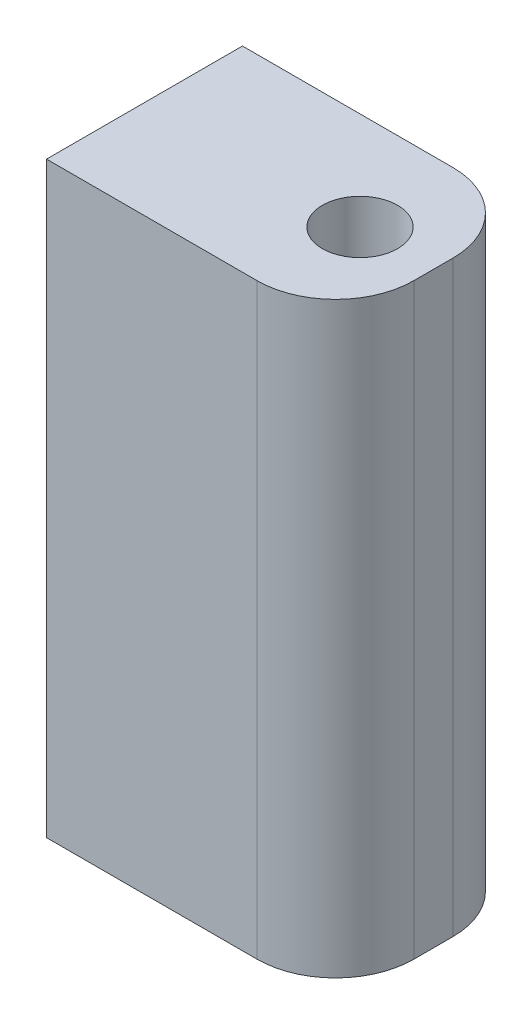
from build123d import *

# Parameters (mm, degrees)
SKETCH1_W                 = 10
SKETCH1_H                 = 19.05
BOSS_EXTRUDE1_DEPTH       = 3.175
F_2_CLEARANCE_HOLE1_D     = 2.4384
F_2_CLEARANCE_HOLE1_DEPTH = 6.35
F_2_CLEARANCE_HOLE1_TIP   = 0.732569267
F_2_CLEARANCE_HOLE2_D     = 2.4384
F_2_CLEARANCE_HOLE2_DEPTH = 6.35
F_2_CLEARANCE_HOLE2_TIP   = 0.732569267
FILLET1_R                 = 1.5875
SKETCH7_W                 = 0.635
SKETCH7_H                 = 6.35
CUT_EXTRUDE1_DEPTH        = 20.05
FILLET2_R                 = 2.54


with BuildPart() as part:
    # Sketch1 → Boss-Extrude1 (new body, symmetric)
    with BuildSketch(Plane.XY):
        Rectangle(SKETCH1_W, SKETCH1_H)
    extrude(amount=BOSS_EXTRUDE1_DEPTH, both=True)

    # #2 Clearance Hole1
    with Locations(Plane(origin=(0, 9.525, 0), x_dir=(-1, 0, 0), z_dir=(0, 1, 0))):
        with Locations((-1.985, 0)):
            Hole(F_2_CLEARANCE_HOLE1_D / 2, depth=F_2_CLEARANCE_HOLE1_DEPTH)
            with Locations((0, 0, -(F_2_CLEARANCE_HOLE1_DEPTH + F_2_CLEARANCE_HOLE1_TIP / 2))):  # 118° drill point
                Cone(0, F_2_CLEARANCE_HOLE1_D / 2, F_2_CLEARANCE_HOLE1_TIP, mode=Mode.SUBTRACT)

    # #2 Clearance Hole2
    with Locations(Plane.ZY.offset(5)):
        with Locations((0, -2.413)):
            Hole(F_2_CLEARANCE_HOLE2_D / 2, depth=F_2_CLEARANCE_HOLE2_DEPTH)
            with Locations((0, 0, -(F_2_CLEARANCE_HOLE2_DEPTH + F_2_CLEARANCE_HOLE2_TIP / 2))):  # 118° drill point
                Cone(0, F_2_CLEARANCE_HOLE2_D / 2, F_2_CLEARANCE_HOLE2_TIP, mode=Mode.SUBTRACT)

    # Fillet1
    fillet1_edges = [part.edges().sort_by_distance(p)[0] for p in [
        (5, 0, 3.175),
        (5, 0, -3.175),
    ]]
    fillet(fillet1_edges, radius=FILLET1_R)

    # Sketch7 → Cut-Extrude1 (cut, through all)
    with BuildSketch(Plane.XZ.offset(9.525)):
        with Locations((4.6825, 0)):
            Rectangle(SKETCH7_W, SKETCH7_H)
    extrude(amount=-CUT_EXTRUDE1_DEPTH, mode=Mode.SUBTRACT)

    # Fillet2
    fillet2_edges = [part.edges().sort_by_distance(p)[0] for p in [
        (4.365, 0, -2.8575),
        (4.365, 0, 2.8575),
    ]]
    fillet(fillet2_edges, radius=FILLET2_R)


solid = part.part
